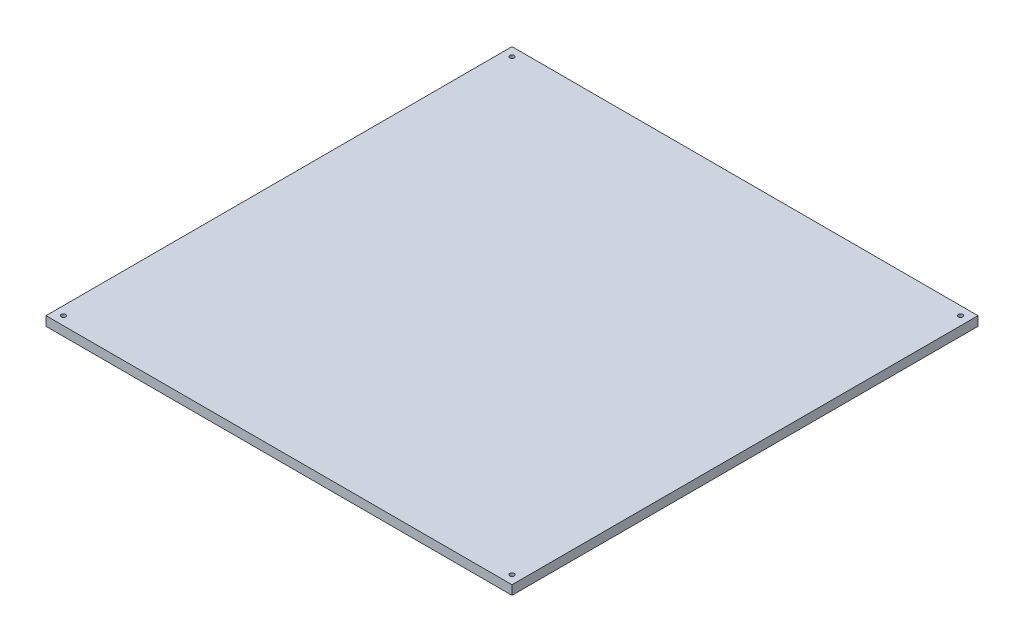
from build123d import *

# Parameters (mm, degrees)
SKETCH1_W           = 320
SKETCH1_H           = 320
SKETCH1_R           = 1.55
BOSS_EXTRUDE1_DEPTH = 6.35


with BuildPart() as part:
    # Sketch1 → Boss-Extrude1 (new body)
    with BuildSketch(Plane(origin=(0, 0, 0), x_dir=(1, 0, 0), z_dir=(0, 1, 0))):
        Rectangle(SKETCH1_W, SKETCH1_H)
        with Locations((154, 154)):
            Circle(SKETCH1_R, mode=Mode.SUBTRACT)
        with Locations((-154, -154)):
            Circle(SKETCH1_R, mode=Mode.SUBTRACT)
        with Locations((154, -154)):
            Circle(SKETCH1_R, mode=Mode.SUBTRACT)
        with Locations((-154, 154)):
            Circle(SKETCH1_R, mode=Mode.SUBTRACT)
    extrude(amount=-BOSS_EXTRUDE1_DEPTH)


solid = part.part
